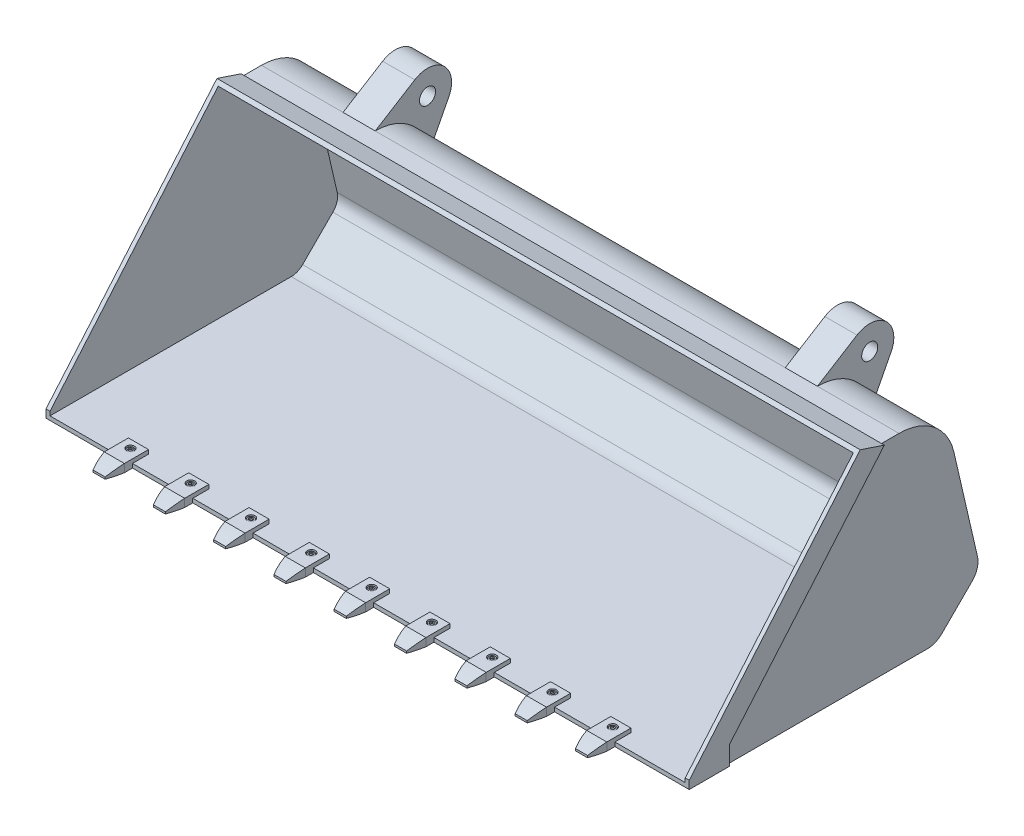
from build123d import *

# Parameters (mm, degrees)
BOSS_EXTRUDE1_DEPTH = 800
CUT_EXTRUDE1_DEPTH  = 790
CUT_EXTRUDE2_DEPTH  = 7
SKETCH4_R           = 20
BOSS_EXTRUDE2_DEPTH = 80
BOSS_EXTRUDE3_DEPTH = 25
SKETCH6_R           = 6
CUT_EXTRUDE3_DEPTH  = 21
SKETCH7_R           = 10
CUT_EXTRUDE4_DEPTH  = 10
SKETCH8_R           = 8.5
BOSS_EXTRUDE4_DEPTH = 8
FILLET1_R           = 1
SKETCH9_R           = 6
BOSS_EXTRUDE5_DEPTH = 8
CUT_EXTRUDE5_DEPTH  = 4
CUT_EXTRUDE7_DEPTH  = 570.349576998
LPATTERN2_COUNT     = 9
LPATTERN2_PITCH     = 150


with BuildPart() as part:
    # Sketch1 → Boss-Extrude1 (new body, symmetric)
    with BuildSketch(Plane(origin=(0, 0, 0), x_dir=(0, 0, -1), z_dir=(1, 0, 0))):
        with BuildLine():
            Line((-300, 20), (-300, 0))
            Line((-300, 0), (300, 0))
            ThreePointArc((300, 0), (319.134171618, 3.806023374), (335.355339059, 14.644660941))
            Line((335.355339059, 14.644660941), (410.714444745, 90.003766626))
            ThreePointArc((410.714444745, 90.003766626), (423.422190482, 111.577237895), (424.077608925, 136.606658403))
            Line((424.077608925, 136.606658403), (365.382588201, 390.842724606))
            ThreePointArc((365.382588201, 390.842724606), (316.122828261, 468.914718957), (228.970779132, 499.349576998))
            Line((228.970779132, 499.349576998), (185.331807465, 499.349576998))
            Line((185.331807465, 499.349576998), (125.331807465, 519.349576998))
            Line((125.331807465, 519.349576998), (-300, 20))
        make_face()
    extrude(amount=BOSS_EXTRUDE1_DEPTH, both=True)

    # Sketch2 → Cut-Extrude1 (cut, symmetric)
    with BuildSketch(Plane(origin=(0, 0, 0), x_dir=(0, 0, -1), z_dir=(1, 0, 0))):
        with BuildLine():
            Line((118.338821698, 511.13964672), (-308.517716387, 10))
            Line((-308.517716387, 10), (300, 10))
            ThreePointArc((300, 10), (315.307337295, 13.0448187), (328.284271247, 21.715728753))
            Line((328.284271247, 21.715728753), (403.643376933, 97.074834438))
            ThreePointArc((403.643376933, 97.074834438), (413.809573523, 114.333611453), (414.333908277, 134.357147859))
            Line((414.333908277, 134.357147859), (355.638887554, 388.593214063))
            ThreePointArc((355.638887554, 388.593214063), (309.897681894, 461.088637389), (228.970779132, 489.349576998))
            Line((228.970779132, 489.349576998), (183.709030863, 489.349576998))
            Line((183.709030863, 489.349576998), (128.56986879, 507.729297689))
            Line((128.56986879, 507.729297689), (118.338821698, 511.13964672))
        make_face()
    extrude(amount=CUT_EXTRUDE1_DEPTH, both=True, mode=Mode.SUBTRACT)

    # Sketch3 → Cut-Extrude2 (cut)
    with BuildSketch(Plane(origin=(800, 0, 0), x_dir=(0, 0, -1), z_dir=(1, 0, 0))):
        with BuildLine():
            Line((-200, 0), (300, 0))
            ThreePointArc((300, 0), (319.134171618, 3.806023374), (335.355339059, 14.644660941))
            Line((335.355339059, 14.644660941), (410.714444745, 90.003766626))
            ThreePointArc((410.714444745, 90.003766626), (423.422190482, 111.577237895), (424.077608925, 136.606658403))
            Line((424.077608925, 136.606658403), (365.382588201, 390.842724606))
            ThreePointArc((365.382588201, 390.842724606), (316.122828261, 468.914718957), (228.970779132, 499.349576998))
            Line((228.970779132, 499.349576998), (185.331807465, 499.349576998))
            Line((185.331807465, 499.349576998), (-200, 46.960943737))
            Line((-200, 46.960943737), (-200, 0))
        make_face()
    cut_extrude2 = extrude(amount=-CUT_EXTRUDE2_DEPTH, mode=Mode.SUBTRACT)

    # Sketch4 → Boss-Extrude2 (add)
    with BuildSketch(Plane(origin=(590, 0, 0), x_dir=(0, 0, -1), z_dir=(1, 0, 0))):
        with BuildLine():
            Line((228.970779132, 499.349576998), (327.355777872, 560.344593376))
            ThreePointArc((327.355777872, 560.344593376), (399.688914543, 553.41808558), (412.301450019, 481.857040871))
            Line((412.301450019, 481.857040871), (365.382588201, 390.842724606))
            ThreePointArc((365.382588201, 390.842724606), (316.122828261, 468.914718957), (228.970779132, 499.349576998))
        make_face()
        with Locations((358.970779132, 509.349576998)):
            Circle(SKETCH4_R, mode=Mode.SUBTRACT)
    boss_extrude2 = extrude(amount=-BOSS_EXTRUDE2_DEPTH)

    # Mirror1: Cut-Extrude2, Boss-Extrude2 across plane
    add(cut_extrude2.mirror(Plane(origin=(0, 0, 0), x_dir=(0, 0, 1), z_dir=(1, 0, 0))), mode=Mode.SUBTRACT)
    add(boss_extrude2.mirror(Plane(origin=(0, 0, 0), x_dir=(0, 0, 1), z_dir=(1, 0, 0))))


with BuildPart() as body_2:
    # Sketch5 → Boss-Extrude3 (new body, symmetric)
    with BuildSketch(Plane(origin=(590, 0, 0), x_dir=(0, 0, -1), z_dir=(1, 0, 0))):
        with BuildLine():
            Line((-260, 20), (-260, 10))
            Line((-260, 10), (-300, 10))
            Line((-300, 10), (-300, 0))
            Line((-300, 0), (-358.047026542, 0))
            Line((-358.047026542, 0), (-358.047026542, 5))
            ThreePointArc((-358.047026542, 5), (-339.537125001, 13.802759941), (-320, 20))
            Line((-320, 20), (-260, 20))
        make_face()
    extrude(amount=BOSS_EXTRUDE3_DEPTH, both=True)


with BuildPart() as cut_extrude3_tool:
    # Sketch6 → Cut-Extrude3 (new body, through all)
    with BuildSketch(Plane(origin=(0, 20, 0), x_dir=(1, 0, 0), z_dir=(0, 1, 0))):
        with Locations((590, -280)):
            Circle(SKETCH6_R)
    extrude(amount=-CUT_EXTRUDE3_DEPTH)


with BuildPart() as part_1:
    add(part.part)

    # Cut-Extrude3: cut by cut_extrude3_tool
    add(cut_extrude3_tool.part, mode=Mode.SUBTRACT)


with BuildPart() as body_2_1:
    add(body_2.part)

    # Cut-Extrude3: cut by cut_extrude3_tool
    add(cut_extrude3_tool.part, mode=Mode.SUBTRACT)

    # Sketch7 → Cut-Extrude4 (cut)
    with BuildSketch(Plane(origin=(0, 20, 0), x_dir=(1, 0, 0), z_dir=(0, 1, 0))):
        with Locations((590, -280)):
            Circle(SKETCH7_R)
    extrude(amount=-CUT_EXTRUDE4_DEPTH, mode=Mode.SUBTRACT)

    # Sketch11 → Cut-Extrude7 (cut, through all)
    with BuildSketch(Plane.XZ):
        with BuildLine():
            Line((615, 320), (623.128275617, 320))
            Line((623.128275617, 320), (623.128275617, 372.326916059))
            Line((623.128275617, 372.326916059), (556.688604754, 372.326916059))
            Line((556.688604754, 372.326916059), (556.688604754, 320))
            Line((556.688604754, 320), (565, 320))
            ThreePointArc((565, 320), (569.142983425, 339.24876519), (575, 358.047026542))
            Line((575, 358.047026542), (605, 358.047026542))
            ThreePointArc((605, 358.047026542), (610.857016575, 339.24876519), (615, 320))
        make_face()
    extrude(amount=-CUT_EXTRUDE7_DEPTH, mode=Mode.SUBTRACT)


with BuildPart() as body_3:
    # Sketch8 → Boss-Extrude4 (new body)
    with BuildSketch(Plane(origin=(0, 10, 0), x_dir=(1, 0, 0), z_dir=(0, 1, 0))):
        with Locations((590, -280)):
            Circle(SKETCH8_R)
    extrude(amount=BOSS_EXTRUDE4_DEPTH)

    # Fillet1
    fillet1_edges = [body_3.edges().sort_by_distance(p)[0] for p in [
        (581.5, 18, 280),
    ]]
    fillet(fillet1_edges, radius=FILLET1_R)

    # Sketch9 → Boss-Extrude5 (add)
    with BuildSketch(Plane(origin=(0, 10, 0), x_dir=(1, 0, 0), z_dir=(0, 1, 0))):
        with Locations((590, -280)):
            Circle(SKETCH9_R)
    extrude(amount=-BOSS_EXTRUDE5_DEPTH)

    # Sketch10 → Cut-Extrude5 (cut)
    with BuildSketch(Plane(origin=(0, 18, 0), x_dir=(1, 0, 0), z_dir=(0, 1, 0))):
        Polygon((595.5, -280), (592.75, -275.236860279), (587.25, -275.236860279), (584.5, -280), (587.25, -284.763139721), (592.75, -284.763139721), align=None)
    extrude(amount=-CUT_EXTRUDE5_DEPTH, mode=Mode.SUBTRACT)


with BuildPart() as lpattern2_1:
    # LPattern2: pattern copy
    add(body_3.part.moved(Location(Vector(-1, 0, 0) * (1 * LPATTERN2_PITCH))))


with BuildPart() as lpattern2_2:
    # LPattern2: pattern copy
    add(body_3.part.moved(Location(Vector(-1, 0, 0) * (2 * LPATTERN2_PITCH))))


with BuildPart() as lpattern2_3:
    # LPattern2: pattern copy
    add(body_3.part.moved(Location(Vector(-1, 0, 0) * (3 * LPATTERN2_PITCH))))


with BuildPart() as lpattern2_4:
    # LPattern2: pattern copy
    add(body_3.part.moved(Location(Vector(-1, 0, 0) * (4 * LPATTERN2_PITCH))))


with BuildPart() as lpattern2_5:
    # LPattern2: pattern copy
    add(body_3.part.moved(Location(Vector(-1, 0, 0) * (5 * LPATTERN2_PITCH))))


with BuildPart() as lpattern2_6:
    # LPattern2: pattern copy
    add(body_3.part.moved(Location(Vector(-1, 0, 0) * (6 * LPATTERN2_PITCH))))


with BuildPart() as lpattern2_7:
    # LPattern2: pattern copy
    add(body_3.part.moved(Location(Vector(-1, 0, 0) * (7 * LPATTERN2_PITCH))))


with BuildPart() as lpattern2_8:
    # LPattern2: pattern copy
    add(body_3.part.moved(Location(Vector(-1, 0, 0) * (8 * LPATTERN2_PITCH))))


with BuildPart() as lpattern2_9:
    # LPattern2: pattern copy
    add(body_2_1.part.moved(Location(Vector(-1, 0, 0) * (1 * LPATTERN2_PITCH))))


with BuildPart() as lpattern2_10:
    # LPattern2: pattern copy
    add(body_2_1.part.moved(Location(Vector(-1, 0, 0) * (2 * LPATTERN2_PITCH))))


with BuildPart() as lpattern2_11:
    # LPattern2: pattern copy
    add(body_2_1.part.moved(Location(Vector(-1, 0, 0) * (3 * LPATTERN2_PITCH))))


with BuildPart() as lpattern2_12:
    # LPattern2: pattern copy
    add(body_2_1.part.moved(Location(Vector(-1, 0, 0) * (4 * LPATTERN2_PITCH))))


with BuildPart() as lpattern2_13:
    # LPattern2: pattern copy
    add(body_2_1.part.moved(Location(Vector(-1, 0, 0) * (5 * LPATTERN2_PITCH))))


with BuildPart() as lpattern2_14:
    # LPattern2: pattern copy
    add(body_2_1.part.moved(Location(Vector(-1, 0, 0) * (6 * LPATTERN2_PITCH))))


with BuildPart() as lpattern2_15:
    # LPattern2: pattern copy
    add(body_2_1.part.moved(Location(Vector(-1, 0, 0) * (7 * LPATTERN2_PITCH))))


with BuildPart() as lpattern2_16:
    # LPattern2: pattern copy
    add(body_2_1.part.moved(Location(Vector(-1, 0, 0) * (8 * LPATTERN2_PITCH))))


solid = Compound([part_1.part, body_2_1.part, body_3.part, lpattern2_1.part, lpattern2_2.part, lpattern2_3.part, lpattern2_4.part, lpattern2_5.part, lpattern2_6.part, lpattern2_7.part, lpattern2_8.part, lpattern2_9.part, lpattern2_10.part, lpattern2_11.part, lpattern2_12.part, lpattern2_13.part, lpattern2_14.part, lpattern2_15.part, lpattern2_16.part])
